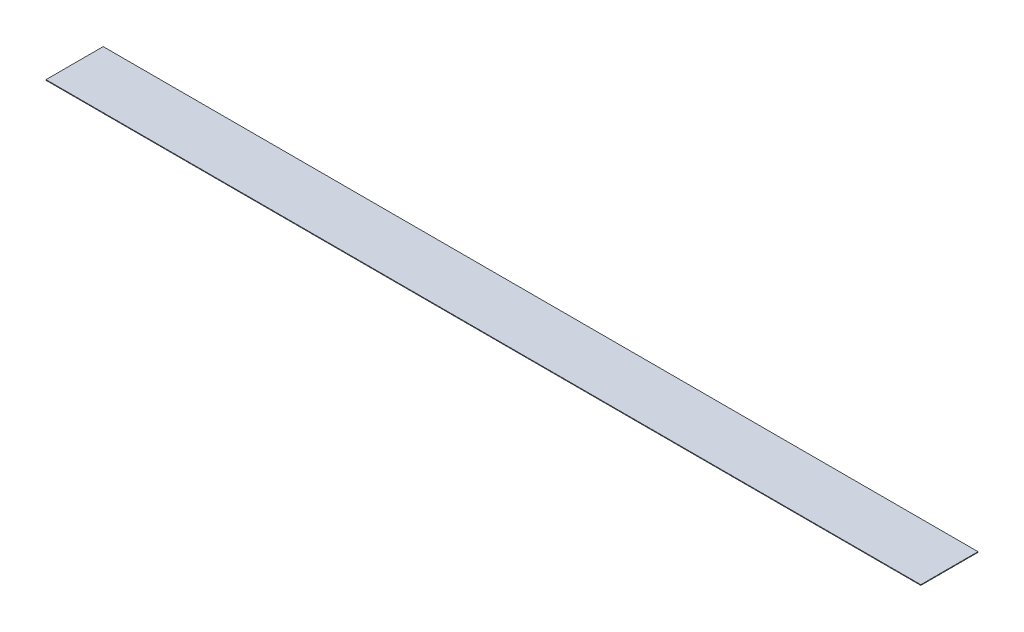
from build123d import *

# Parameters (mm, degrees)
SKETCH1_W      = 1064
SKETCH1_H      = 69.56
EXTRUDE1_DEPTH = 0.762


with BuildPart() as part:
    # Sketch1 → Extrude1 (new body)
    with BuildSketch(Plane(origin=(0, 0, 0), x_dir=(1, 0, 0), z_dir=(0, 1, 0))):
        with Locations((532, 0)):
            Rectangle(SKETCH1_W, SKETCH1_H)
    extrude(amount=EXTRUDE1_DEPTH)


solid = part.part
